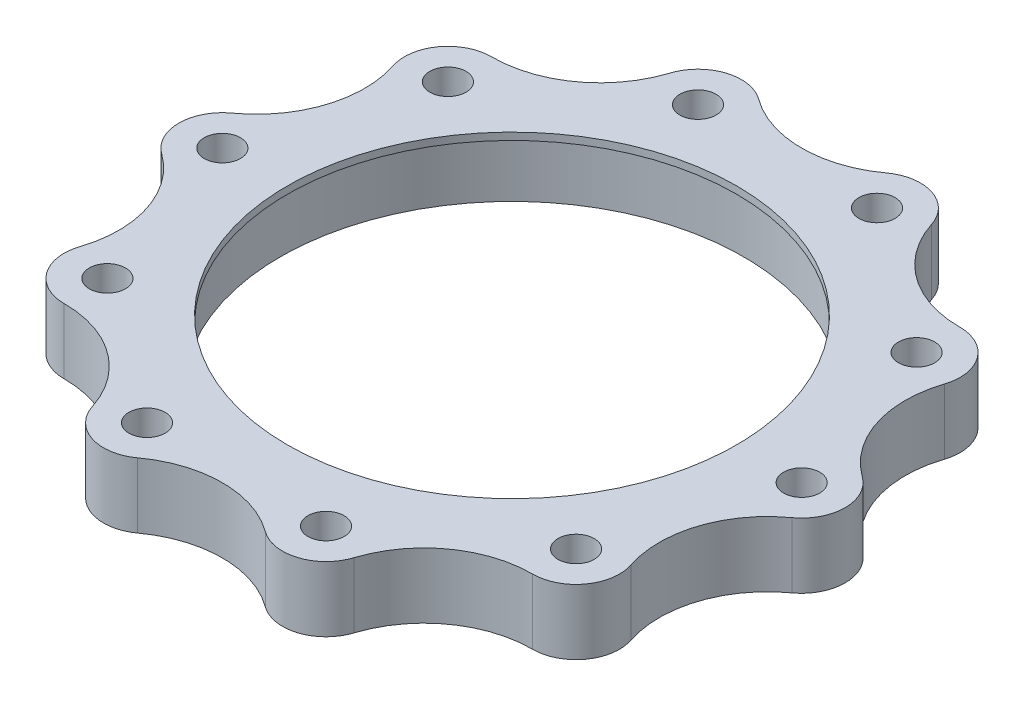
from build123d import *

# Parameters (mm, degrees)
SKETCH_1_R      = 1.25
SKETCH_1_R_2    = 16
EXTRUDE_1_DEPTH = 4.5
SKETCH_2_R      = 16
SKETCH_2_R_2    = 15.5
EXTRUDE_2_DEPTH = 0.5


with BuildPart() as part:
    # 草图1 → 凸台-拉伸1 (new body)
    with BuildSketch(Plane(origin=(0, 0, 0), x_dir=(1, 0, 0), z_dir=(0, 1, 0))):
        with BuildLine():
            ThreePointArc((21.75410191, -2.433747417), (23, 0), (21.75410191, 2.433747417))
            ThreePointArc((21.75410191, 2.433747417), (19.021130326, 6.180339887), (19.029958982, 10.81779726))
            ThreePointArc((19.029958982, 10.81779726), (18.607390871, 13.519060803), (16.168917304, 14.7556833))
            ThreePointArc((16.168917304, 14.7556833), (11.755705046, 16.180339887), (9.037018527, 19.937311066))
            ThreePointArc((9.037018527, 19.937311066), (7.107390871, 21.874299875), (4.407755848, 21.44144969))
            ThreePointArc((4.407755848, 21.44144969), (0, 20), (-4.407755848, 21.44144969))
            ThreePointArc((-4.407755848, 21.44144969), (-7.107390871, 21.874299875), (-9.037018527, 19.937311066))
            ThreePointArc((-9.037018527, 19.937311066), (-11.755705046, 16.180339887), (-16.168917304, 14.7556833))
            ThreePointArc((-16.168917304, 14.7556833), (-18.607390871, 13.519060803), (-19.029958982, 10.81779726))
            ThreePointArc((-19.029958982, 10.81779726), (-19.021130326, 6.180339887), (-21.75410191, 2.433747417))
            ThreePointArc((-21.75410191, 2.433747417), (-23, 0), (-21.75410191, -2.433747417))
            ThreePointArc((-21.75410191, -2.433747417), (-19.021130326, -6.180339887), (-19.029958982, -10.81779726))
            ThreePointArc((-19.029958982, -10.81779726), (-18.607390871, -13.519060803), (-16.168917304, -14.7556833))
            ThreePointArc((-16.168917304, -14.7556833), (-11.755705046, -16.180339887), (-9.037018527, -19.937311066))
            ThreePointArc((-9.037018527, -19.937311066), (-7.107390871, -21.874299875), (-4.407755848, -21.44144969))
            ThreePointArc((-4.407755848, -21.44144969), (0, -20), (4.407755848, -21.44144969))
            ThreePointArc((4.407755848, -21.44144969), (7.107390871, -21.874299875), (9.037018527, -19.937311066))
            ThreePointArc((9.037018527, -19.937311066), (11.755705046, -16.180339887), (16.168917304, -14.7556833))
            ThreePointArc((16.168917304, -14.7556833), (18.607390871, -13.519060803), (19.029958982, -10.81779726))
            ThreePointArc((19.029958982, -10.81779726), (19.021130326, -6.180339887), (21.75410191, -2.433747417))
        make_face()
        with Locations((20, 0)):
            Circle(SKETCH_1_R, mode=Mode.SUBTRACT)
        with Locations((16.180339887, -11.755705046)):
            Circle(SKETCH_1_R, mode=Mode.SUBTRACT)
        with Locations((6.180339887, -19.021130326)):
            Circle(SKETCH_1_R, mode=Mode.SUBTRACT)
        with Locations((-6.180339887, -19.021130326)):
            Circle(SKETCH_1_R, mode=Mode.SUBTRACT)
        with Locations((-16.180339887, -11.755705046)):
            Circle(SKETCH_1_R, mode=Mode.SUBTRACT)
        with Locations((-20, 0)):
            Circle(SKETCH_1_R, mode=Mode.SUBTRACT)
        with Locations((-16.180339887, 11.755705046)):
            Circle(SKETCH_1_R, mode=Mode.SUBTRACT)
        with Locations((-6.180339887, 19.021130326)):
            Circle(SKETCH_1_R, mode=Mode.SUBTRACT)
        with Locations((6.180339887, 19.021130326)):
            Circle(SKETCH_1_R, mode=Mode.SUBTRACT)
        with Locations((16.180339887, 11.755705046)):
            Circle(SKETCH_1_R, mode=Mode.SUBTRACT)
        Circle(SKETCH_1_R_2, mode=Mode.SUBTRACT)
    extrude(amount=EXTRUDE_1_DEPTH)

    # 草图2 → 凸台-拉伸2 (add)
    with BuildSketch(Plane(origin=(0, 4.5, 0), x_dir=(1, 0, 0), z_dir=(0, 1, 0))):
        Circle(SKETCH_2_R)
        Circle(SKETCH_2_R_2, mode=Mode.SUBTRACT)
    extrude(amount=-EXTRUDE_2_DEPTH)


solid = part.part
